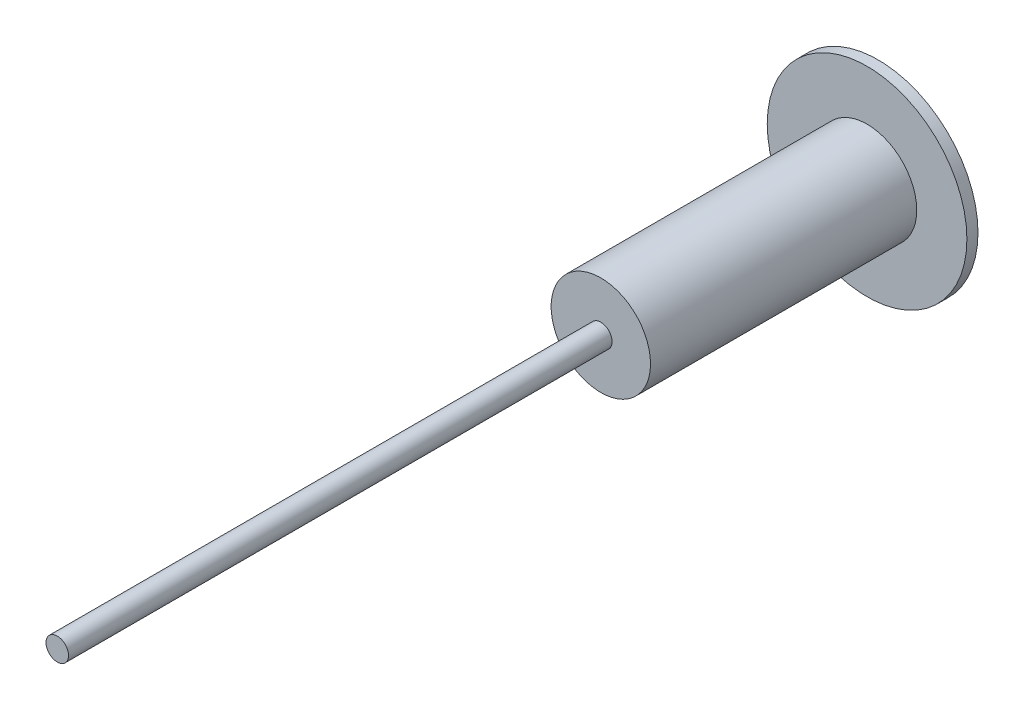
from build123d import *

# Parameters (mm, degrees)
SKETCH1_R                = 50.8
BOSS_EXTRUDE1_DEPTH      = 1650
BOSS_EXTRUDE1_DEPTH_BACK = 2050
SKETCH2_R                = 450
BOSS_EXTRUDE2_DEPTH      = 50
SKETCH3_R                = 223.901
BOSS_EXTRUDE3_DEPTH      = 1200


with BuildPart() as part:
    # Sketch1 → Boss-Extrude1 (new body, two sides)
    with BuildSketch(Plane.XY) as boss_extrude1_sk:
        Circle(SKETCH1_R)
    extrude(amount=BOSS_EXTRUDE1_DEPTH)
    extrude(boss_extrude1_sk.sketch, amount=-BOSS_EXTRUDE1_DEPTH_BACK)

    # Sketch2 → Boss-Extrude2 (add)
    with BuildSketch(Plane.XY.offset(-2050)):
        Circle(SKETCH2_R)
    extrude(amount=BOSS_EXTRUDE2_DEPTH)

    # Sketch3 → Boss-Extrude3 (add)
    with BuildSketch(Plane.XY.offset(-2000)):
        Circle(SKETCH3_R)
    extrude(amount=BOSS_EXTRUDE3_DEPTH)


solid = part.part
